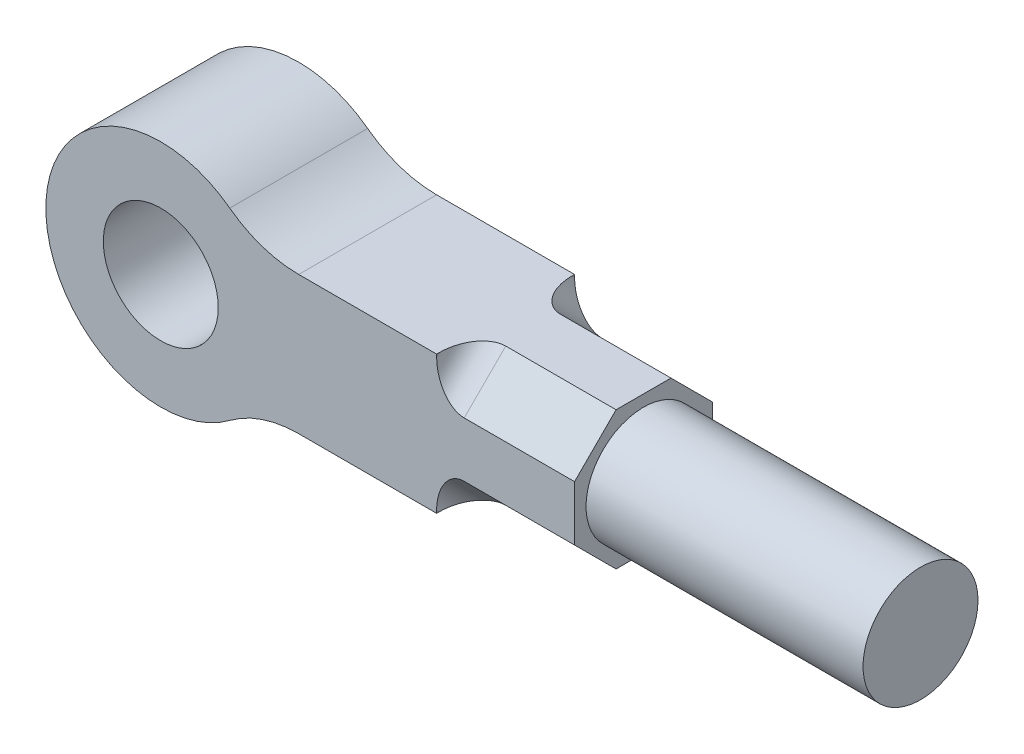
from build123d import *

# Parameters (mm, degrees)
SKETCH2_R           = 250
BOSS_EXTRUDE1_DEPTH = 600
CUT_EXTRUDE1_DEPTH  = 600
SKETCH5_4_R         = 250
BOSS_EXTRUDE2_DEPTH = 1205
FILLET1_R           = 120


with BuildPart() as part:
    # Sketch2 → Boss-Extrude1 (new body)
    with BuildSketch(Plane.XY):
        with BuildLine():
            Line((600, 300), (1800, 300))
            Line((1800, 300), (1800, -300))
            Line((1800, -300), (600, -300))
            ThreePointArc((600, -300), (441.886116992, -325.658350975), (300, -400))
            ThreePointArc((300, -400), (-500, 0), (300, 400))
            ThreePointArc((300, 400), (441.886116992, 325.658350975), (600, 300))
        make_face()
        Circle(SKETCH2_R, mode=Mode.SUBTRACT)
    extrude(amount=BOSS_EXTRUDE1_DEPTH)

    # Sketch5 → Cut-Extrude1 (cut)
    with BuildSketch(Plane(origin=(1800, 0, 0), x_dir=(0, 0, -1), z_dir=(1, 0, 0))):
        Polygon((-600, 119.4), (-419.4, 300), (-600, 300), align=None)
        Polygon((-113.09603494, 300), (-117.263350095, 300), (-180.6, 300), (0, 119.4), (0, 300), align=None)
        Polygon((0, -300), (0, -119.4), (-180.6, -300), align=None)
        Polygon((-419.4, -300), (-600, -119.4), (-600, -300), align=None)
    extrude(amount=-CUT_EXTRUDE1_DEPTH, mode=Mode.SUBTRACT)

    # Sketch5_4 → Boss-Extrude2 (add)
    with BuildSketch(Plane(origin=(1800, 0, 0), x_dir=(0, 0, -1), z_dir=(1, 0, 0))):
        with Locations((-300, 0)):
            Circle(SKETCH5_4_R)
    extrude(amount=BOSS_EXTRUDE2_DEPTH)

    # Fillet1
    fillet1_edges = [part.edges().sort_by_distance(p)[0] for p in [
        (1200, -209.7, 509.7),
        (1200, -209.7, 90.3),
        (1200, 209.7, 90.3),
        (1200, 209.7, 509.7),
    ]]
    fillet(fillet1_edges, radius=FILLET1_R)


solid = part.part
